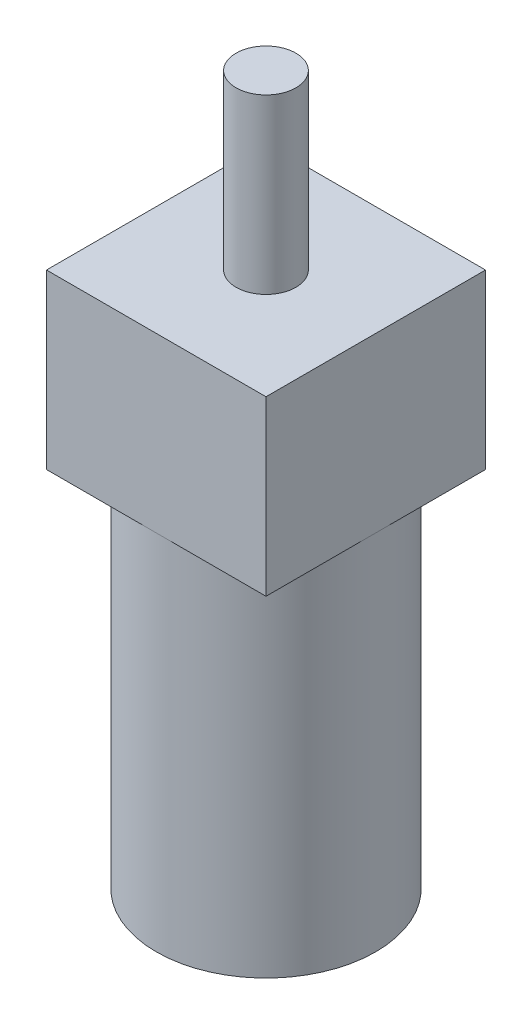
from build123d import *

# Parameters (mm, degrees)
SKETCH1_W           = 6.05
SKETCH1_H           = 20
SKETCH2_W           = 12.1
SKETCH2_H           = 12.1
BOSS_EXTRUDE1_DEPTH = 9.525
SKETCH3_R           = 1.652922186
BOSS_EXTRUDE2_DEPTH = 9.525


with BuildPart() as part:
    # Sketch1 → Revolve1 (revolve)
    with BuildSketch(Plane.XY):
        with Locations((-3.025, 0)):
            Rectangle(SKETCH1_W, SKETCH1_H)
    revolve(axis=Axis((0, 10, 0), (0, -1, 0)))

    # Sketch2 → Boss-Extrude1 (add)
    with BuildSketch(Plane(origin=(0, 10, 0), x_dir=(1, 0, 0), z_dir=(0, 1, 0))):
        Rectangle(SKETCH2_W, SKETCH2_H)
    extrude(amount=BOSS_EXTRUDE1_DEPTH)

    # Sketch3 → Boss-Extrude2 (add)
    with BuildSketch(Plane(origin=(0, 19.525, 0), x_dir=(1, 0, 0), z_dir=(0, 1, 0))):
        Circle(SKETCH3_R)
    extrude(amount=BOSS_EXTRUDE2_DEPTH)


solid = part.part
